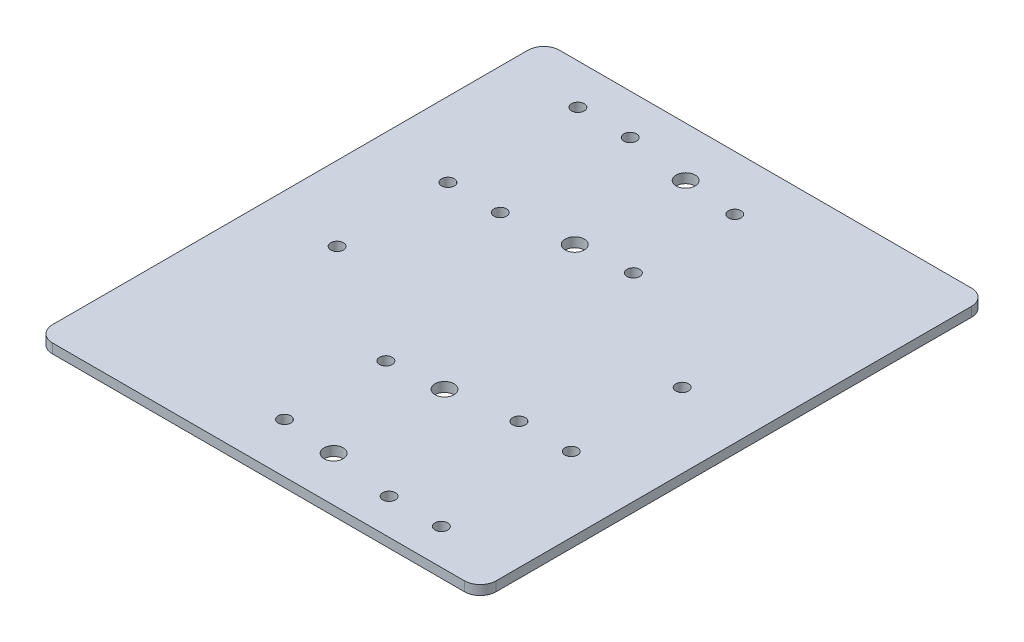
from build123d import *

# Parameters (mm, degrees)
SKETCH1_W           = 140
SKETCH1_H           = 160
BOSS_EXTRUDE1_DEPTH = 3
SKETCH2_R           = 2
SKETCH2_R_2         = 3
CUT_EXTRUDE1_DEPTH  = 4
FILLET1_R           = 5


with BuildPart() as part:
    # Sketch1 → Boss-Extrude1 (new body)
    with BuildSketch(Plane(origin=(0, 0, 0), x_dir=(1, 0, 0), z_dir=(0, 1, 0))):
        Rectangle(SKETCH1_W, SKETCH1_H)
    extrude(amount=BOSS_EXTRUDE1_DEPTH)

    # Sketch2 → Cut-Extrude1 (cut, through all)
    with BuildSketch(Plane(origin=(0, 3, 0), x_dir=(1, 0, 0), z_dir=(0, 1, 0))):
        with Locations((-30, 26.3)):
            Circle(SKETCH2_R)
        with Locations((-30, 67.3)):
            Circle(SKETCH2_R)
        with Locations((7.5, 62.8)):
            Circle(SKETCH2_R)
        with Locations((7.5, 30.8)):
            Circle(SKETCH2_R)
        with Locations((30, -68.8)):
            Circle(SKETCH2_R)
        with Locations((-7.5, -64.3)):
            Circle(SKETCH2_R)
        with Locations((30, -27.8)):
            Circle(SKETCH2_R)
        with Locations((-7.5, -32.3)):
            Circle(SKETCH2_R)
        with Locations((46.5, -27.8)):
            Circle(SKETCH2_R)
        with Locations((46.5, -68.8)):
            Circle(SKETCH2_R)
        with Locations((-46.5, 26.3)):
            Circle(SKETCH2_R)
        with Locations((-46.5, 67.3)):
            Circle(SKETCH2_R)
        with Locations((46.5, 7.2)):
            Circle(SKETCH2_R)
        with Locations((-46.5, -8.7)):
            Circle(SKETCH2_R)
        with Locations((9.5, -65.8)):
            Circle(SKETCH2_R_2)
        with Locations((9.5, -30.8)):
            Circle(SKETCH2_R_2)
        with Locations((-9.5, 64.3)):
            Circle(SKETCH2_R_2)
        with Locations((-9.5, 29.3)):
            Circle(SKETCH2_R_2)
    extrude(amount=-CUT_EXTRUDE1_DEPTH, mode=Mode.SUBTRACT)

    # Fillet1
    fillet1_edges = [part.edges().sort_by_distance(p)[0] for p in [
        (-70, 1.5, -80),
        (70, 1.5, -80),
        (70, 1.5, 80),
        (-70, 1.5, 80),
    ]]
    fillet(fillet1_edges, radius=FILLET1_R)


solid = part.part
